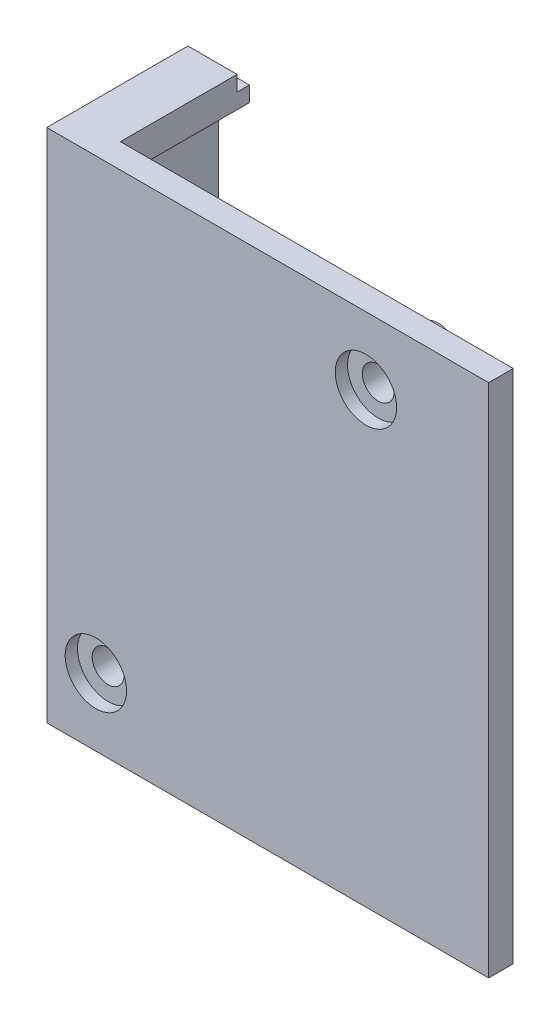
from build123d import *

# Parameters (mm, degrees)
SKETCH_1_W          = 36
SKETCH_1_H          = 42
EXTRUDE_1_DEPTH     = 2
EXTRUDE_2_DEPTH     = 9.5
EXTRUDE_3_DEPTH     = 10.5
CUT_EXTRUDE_1_REACH = 43.731
SKETCH_4_R          = 1.75
SKETCH_4_R_2        = 1.3
EXTRUDE_4_DEPTH     = 3.9
CUT_EXTRUDE_2_REACH = 33.5
SKETCH_4_2_R        = 1.3
SKETCH_5_R          = 2.5
CUT_EXTRUDE_3_DEPTH = 1
SKETCH_6_R          = 2
CUT_EXTRUDE_4_DEPTH = 1.5


with BuildPart() as part:
    # 草图1 → 凸台-拉伸1 (new body)
    with BuildSketch(Plane.XY):
        with Locations((3, 0)):
            Rectangle(SKETCH_1_W, SKETCH_1_H)
    extrude(amount=EXTRUDE_1_DEPTH)

    # 草图2 → 凸台-拉伸2 (add)
    with BuildSketch(Plane(origin=(0, 0, 0), x_dir=(-1, 0, 0), z_dir=(0, 0, -1))):
        Polygon((15, -21), (15, 21), (11, 21), (11, 18.5), (13.5, 18.5), (13.5, -18.5), (11, -18.5), (11, -21), align=None)
    extrude(amount=EXTRUDE_2_DEPTH)

    # 草图2<3> → 凸台-拉伸3 (add)
    with BuildSketch(Plane(origin=(0, 0, 0), x_dir=(-1, 0, 0), z_dir=(0, 0, -1))):
        Polygon((14, 19.75), (11, 19.75), (11, 18.5), (13.5, 18.5), (13.5, -18.5), (11, -18.5), (11, -19.75), (14, -19.75), align=None)
    extrude(amount=EXTRUDE_3_DEPTH)

    # 草图3 → 切除-拉伸1 (cut, up to next)
    with BuildSketch(Plane(origin=(-13.5, 0, 0), x_dir=(0, 0, -1), z_dir=(1, 0, 0)), mode=Mode.PRIVATE) as cut_extrude_1_sk1:
        with BuildLine():
            Line((2.35, -3.4), (2.35, 3.4))
            ThreePointArc((2.35, 3.4), (3.95, 5), (5.55, 3.4))
            Line((5.55, 3.4), (5.55, -3.4))
            ThreePointArc((5.55, -3.4), (3.95, -5), (2.35, -3.4))
        make_face()
    cut_extrude_1_tool1 = extrude(cut_extrude_1_sk1.sketch, amount=-CUT_EXTRUDE_1_REACH, mode=Mode.PRIVATE) & part.part
    add(cut_extrude_1_tool1.solids().sort_by_distance((-13.5, 0, -3.95))[0], mode=Mode.SUBTRACT)

    # 草图4 → 凸台-拉伸4 (add)
    # profile 1 of 2: a face of its own
    with BuildSketch(Plane(origin=(0, 0, 0), x_dir=(-1, 0, 0), z_dir=(0, 0, -1))):
        with Locations((11, -15.5)):
            Circle(SKETCH_4_R)
        with Locations((11, -15.5)):
            Circle(SKETCH_4_R_2, mode=Mode.SUBTRACT)
    # profile 2 of 2: a face of its own
    with BuildSketch(Plane(origin=(0, 0, 0), x_dir=(-1, 0, 0), z_dir=(0, 0, -1))):
        with Locations((-11, 15.5)):
            Circle(SKETCH_4_R)
        with Locations((-11, 15.5)):
            Circle(SKETCH_4_R_2, mode=Mode.SUBTRACT)
    extrude(amount=EXTRUDE_4_DEPTH)

    # 草图4<2> → 切除-拉伸2 (cut, up to next)
    with BuildSketch(Plane(origin=(0, 0, 0), x_dir=(-1, 0, 0), z_dir=(0, 0, -1)), mode=Mode.PRIVATE) as cut_extrude_2_sk1:
        with Locations((11, -15.5)):
            Circle(SKETCH_4_2_R)
    cut_extrude_2_tool1 = extrude(cut_extrude_2_sk1.sketch, amount=-CUT_EXTRUDE_2_REACH, mode=Mode.PRIVATE) & part.part
    # 草图4<2> → 切除-拉伸2 (cut, up to next)
    with BuildSketch(Plane(origin=(0, 0, 0), x_dir=(-1, 0, 0), z_dir=(0, 0, -1)), mode=Mode.PRIVATE) as cut_extrude_2_sk2:
        with Locations((-11, 15.5)):
            Circle(SKETCH_4_2_R)
    cut_extrude_2_tool2 = extrude(cut_extrude_2_sk2.sketch, amount=-CUT_EXTRUDE_2_REACH, mode=Mode.PRIVATE) & part.part
    add(cut_extrude_2_tool1.solids().sort_by_distance((-11, -15.5, 0))[0], mode=Mode.SUBTRACT)
    add(cut_extrude_2_tool2.solids().sort_by_distance((11, 15.5, 0))[0], mode=Mode.SUBTRACT)

    # 草图5 → 切除-拉伸3 (cut)
    with BuildSketch(Plane.XY.offset(2)):
        with Locations((11, 15.5)):
            Circle(SKETCH_5_R)
        with Locations((-11, -15.5)):
            Circle(SKETCH_5_R)
    extrude(amount=-CUT_EXTRUDE_3_DEPTH, mode=Mode.SUBTRACT)

    # 草图6 → 切除-拉伸4 (cut)
    with BuildSketch(Plane(origin=(0, 0, 0), x_dir=(-1, 0, 0), z_dir=(0, 0, -1))):
        with Locations((-8.15, 0)):
            Circle(SKETCH_6_R)
    extrude(amount=-CUT_EXTRUDE_4_DEPTH, mode=Mode.SUBTRACT)


solid = part.part
